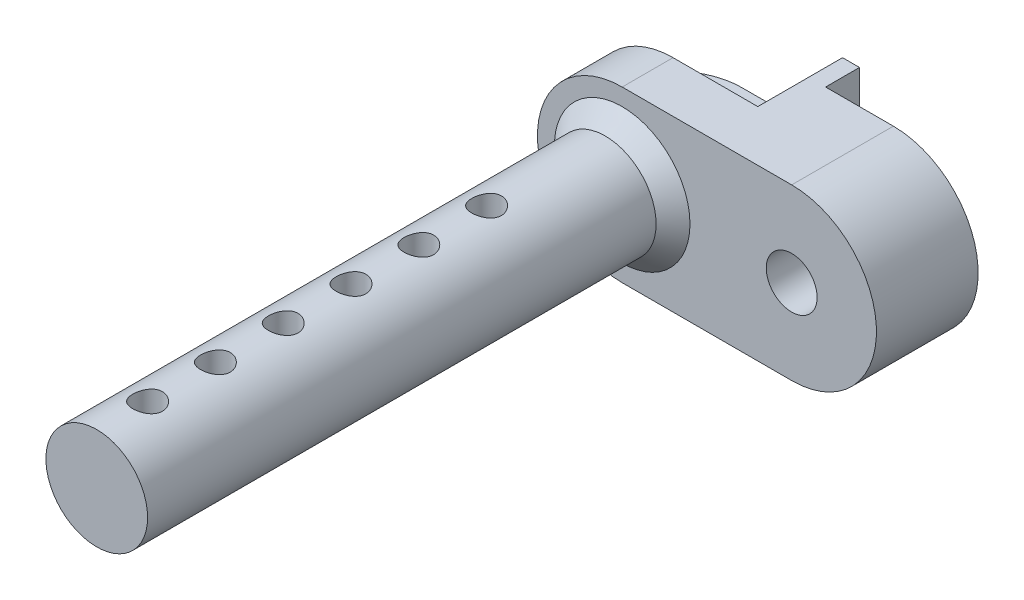
from build123d import *

# Parameters (mm, degrees)
VYSUNOUT1_DEPTH          = 8
SKICA2_R                 = 3
VYSUNOUT2_DEPTH          = 31
M3_Z_VITOV_D_RY1_D       = 3
ZKOSIT1_SIZE             = 1
SKICA5_W                 = 10.533076429
SKICA5_H                 = 13.637336759
ODEBRAT_VYSUNUT_M1_DEPTH = 2
ODEBRAT_VYSUNUT_M2_DEPTH = 2
SKICA7_W                 = 10.597302505
SKICA7_H                 = 5.566259902
ODEBRAT_VYSUNUT_M3_DEPTH = 5
ZAOBLIT1_R               = 4
SKICA8_R                 = 0.875
ODEBRAT_VYSUNUT_M4_DEPTH = 6
LINPOLE1_COUNT           = 6
LINPOLE1_PITCH           = 4
LINPOLE1_COUNT_DIR2      = 4
LINPOLE1_PITCH_DIR2      = 50


with BuildPart() as part:
    # Skica1 → Vysunout1 (new body)
    with BuildSketch(Plane.XY):
        with BuildLine():
            Line((0, 0), (10, 0))
            ThreePointArc((10, 0), (15, -5), (10, -10))
            Line((10, -10), (0, -10))
            ThreePointArc((0, -10), (-5, -5), (0, 0))
        make_face()
    extrude(amount=VYSUNOUT1_DEPTH)

    # Skica2 → Vysunout2 (add)
    with BuildSketch(Plane.XY.offset(8)):
        with Locations((0, -5)):
            Circle(SKICA2_R)
    extrude(amount=VYSUNOUT2_DEPTH)

    # M3 závitové díry1 (through all)
    with Locations(Plane.XY.offset(8)):
        with Locations((10, -5)):
            Hole(M3_Z_VITOV_D_RY1_D / 2)

    # Zkosit1
    zkosit1_edges = [part.edges().sort_by_distance(p)[0] for p in [
        (-3, -5, 8),
    ]]
    chamfer(zkosit1_edges, length=ZKOSIT1_SIZE)

    # Skica5 → Odebrat vysunutím1 (cut)
    with BuildSketch(Plane(origin=(0, 0, 0), x_dir=(-1, 0, 0), z_dir=(0, 0, -1))):
        with Locations((-11.266538215, -4.925069579)):
            Rectangle(SKICA5_W, SKICA5_H)
    extrude(amount=-ODEBRAT_VYSUNUT_M1_DEPTH, mode=Mode.SUBTRACT)

    # Skica6 → Odebrat vysunutím2 (cut)
    with BuildSketch(Plane(origin=(0, 0, 2), x_dir=(-1, 0, 0), z_dir=(0, 0, -1))):
        with BuildLine():
            Line((-6, -1), (-6, -9))
            Line((-6, -9), (-10, -9))
            ThreePointArc((-10, -9), (-14, -5), (-10, -1))
            Line((-10, -1), (-6, -1))
        make_face()
    extrude(amount=-ODEBRAT_VYSUNUT_M2_DEPTH, mode=Mode.SUBTRACT)

    # Skica7 → Odebrat vysunutím3 (cut)
    with BuildSketch(Plane(origin=(0, 0, 0), x_dir=(-1, 0, 0), z_dir=(0, 0, -1))):
        with Locations((0.298651253, -1.716870049)):
            Rectangle(SKICA7_W, SKICA7_H)
        with Locations((0.298651253, -8.283129951)):
            Rectangle(SKICA7_W, SKICA7_H)
    extrude(amount=-ODEBRAT_VYSUNUT_M3_DEPTH, mode=Mode.SUBTRACT)

    # Zaoblit1
    zaoblit1_edges = [part.edges().sort_by_distance(p)[0] for p in [
        (-5, -5, 0),
    ]]
    fillet(zaoblit1_edges, radius=ZAOBLIT1_R)

    # Skica8 → Odebrat vysunutím4 (cut)
    with BuildSketch(Plane(origin=(0, -8, 0), x_dir=(-1, 0, 0), z_dir=(0, 1, 0))):
        with Locations(Location((0, 36, 0), (0, 0, 270))):  # turned: the seam where the file's is
            Circle(SKICA8_R)
    odebrat_vysunut_m4 = extrude(amount=ODEBRAT_VYSUNUT_M4_DEPTH, mode=Mode.SUBTRACT)

    # LinPole1: Odebrat vysunut_m4 6 × 4
    with Locations(*[Vector(0, 0, -1) * (i * LINPOLE1_PITCH) + Vector(0, 0, -1) * (j * LINPOLE1_PITCH_DIR2) for i in range(LINPOLE1_COUNT) for j in range(LINPOLE1_COUNT_DIR2) if (i, j) != (0, 0)]):
        add(odebrat_vysunut_m4, mode=Mode.SUBTRACT)


solid = part.part
